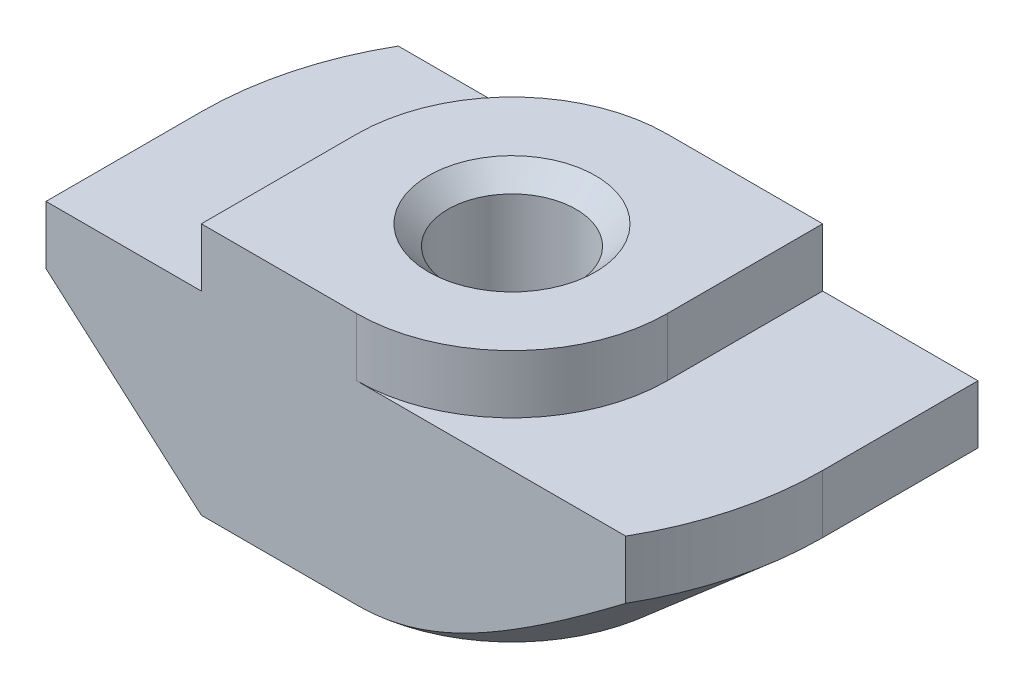
from build123d import *

# Parameters (mm, degrees)
EXTRUDE_1_DEPTH     = 4
CUT_EXTRUDE_1_DEPTH = 1.5
CUT_EXTRUDE_2_DEPTH = 6


with BuildPart() as part:
    # Эскиз1 → Бобышка-Вытянуть1 (new body, symmetric)
    with BuildSketch(Plane.XY):
        Polygon((4, 0), (-4, 0), (-4, -1.5), (-8, -1.5), (-8, -6.5), (8, -6.5), (8, -1.5), (4, -1.5), align=None)
    extrude(amount=EXTRUDE_1_DEPTH, both=True)

    # Эскиз3 → Отверстие обработанное метчиком M42 (revolve, cut)
    with BuildSketch(Plane(origin=(0, 0, 0), x_dir=(0, 0, 1), z_dir=(1, 0, 0))):
        Polygon((0, 0), (0, 6.5), (2.15, 6.5), (1.65, 6), (1.65, 0.5), (2.15, 0), align=None)
    revolve(axis=Axis((0, 6.35, 0), (0, -1, 0)), mode=Mode.SUBTRACT)

    # Эскиз4 → Вырез-Вытянуть1 (cut)
    with BuildSketch(Plane(origin=(0, 0, 0), x_dir=(1, 0, 0), z_dir=(0, 1, 0))):
        with BuildLine():
            Line((-4, 4), (-4, 0))
            ThreePointArc((-4, 0), (-2.828427125, 2.828427125), (0, 4))
            Line((0, 4), (-4, 4))
        make_face()
        with BuildLine():
            Line((0, -4), (4, -4))
            Line((4, -4), (4, 0))
            ThreePointArc((4, 0), (2.828427125, -2.828427125), (0, -4))
        make_face()
    extrude(amount=-CUT_EXTRUDE_1_DEPTH, mode=Mode.SUBTRACT)

    # Эскиз5 → Вырез-Вытянуть2 (cut, through all)
    with BuildSketch(Plane(origin=(0, -1.5, 0), x_dir=(1, 0, 0), z_dir=(0, 1, 0))):
        with BuildLine():
            Line((-8, 0), (-8, 4))
            Line((-8, 4), (-6.92820323, 4))
            ThreePointArc((-6.92820323, 4), (-7.72740661, 2.070552361), (-8, 0))
        make_face()
        with BuildLine():
            Line((8, 0), (8, -4))
            Line((8, -4), (6.92820323, -4))
            ThreePointArc((6.92820323, -4), (7.72740661, -2.070552361), (8, 0))
        make_face()
    extrude(amount=-CUT_EXTRUDE_2_DEPTH, mode=Mode.SUBTRACT)

    # Вырез-По траектории1: sweep along a path in Эскиз7
    with BuildLine(Plane.XZ.offset(6.5)) as sweep_1_path:
        Line((0, 8), (-8, 8))
        Line((-8, 8), (-8, 0))
        ThreePointArc((-8, 0), (-5.656854249, -5.656854249), (0, -8))
        Line((0, -8), (8, -8))
        Line((8, -8), (8, 0))
        ThreePointArc((8, 0), (5.656854249, 5.656854249), (0, 8))
    # Эскиз6 → Вырез-По траектории1 (sweep, cut)
    with BuildSketch(Plane.XY.offset(4)):
        Polygon((-8, -3), (-8, -6.5), (-4, -6.5), align=None)
    sweep(path=sweep_1_path.line, transition=Transition.RIGHT, mode=Mode.SUBTRACT)


solid = part.part
